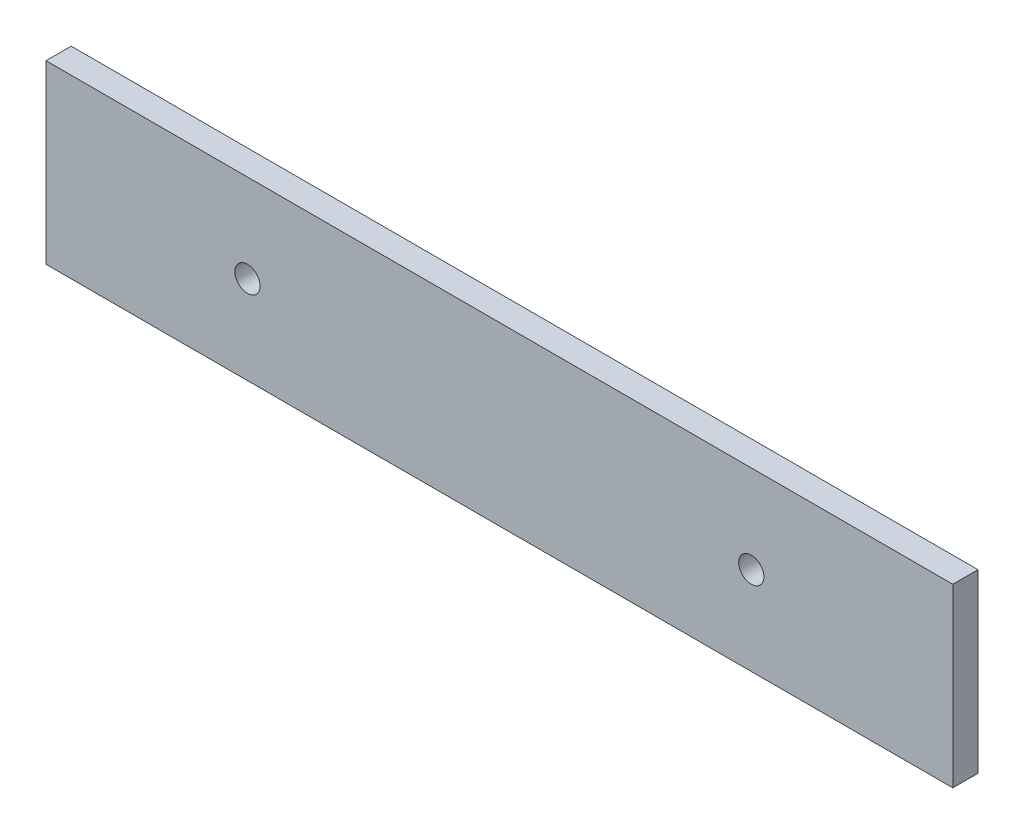
from build123d import *

# Parameters (mm, degrees)
ESQUISSE1_W        = 360
ESQUISSE1_H        = 70
ESQUISSE1_R        = 5
BOSS_EXTRU_1_DEPTH = 10


with BuildPart() as part:
    # Esquisse1 → Boss.-Extru.1 (new body)
    with BuildSketch(Plane.XY):
        with Locations((-327.00254381, 120.689655172)):
            Rectangle(ESQUISSE1_W, ESQUISSE1_H)
        with Locations((-427.00254381, 120.689655172)):
            Circle(ESQUISSE1_R, mode=Mode.SUBTRACT)
        with Locations((-227.00254381, 120.689655172)):
            Circle(ESQUISSE1_R, mode=Mode.SUBTRACT)
    extrude(amount=BOSS_EXTRU_1_DEPTH)


solid = part.part
